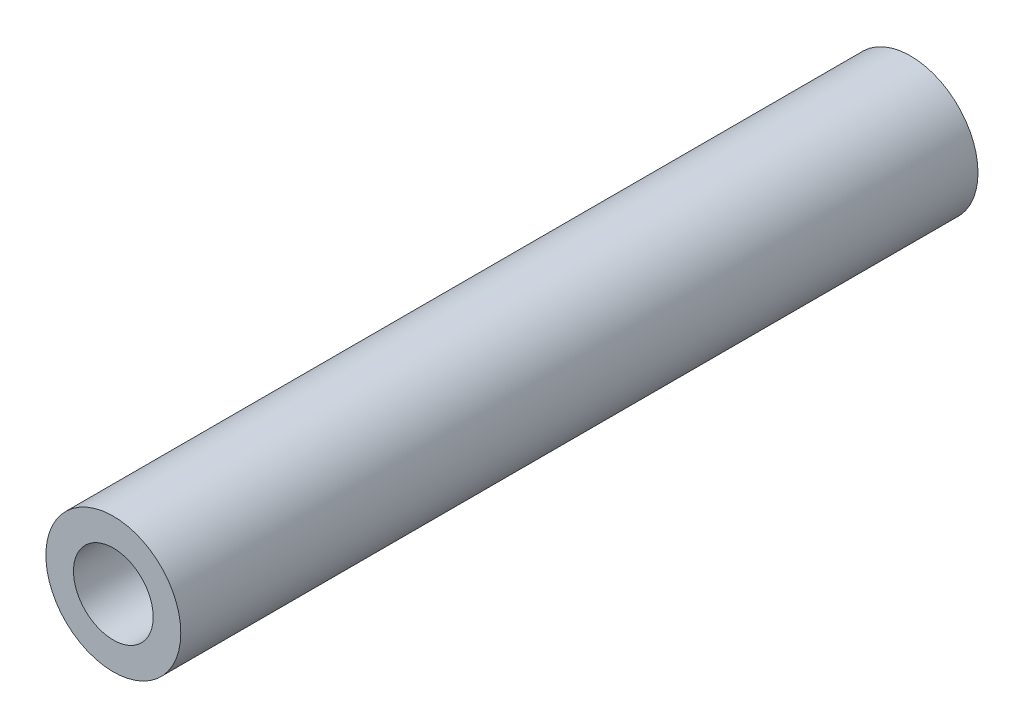
from build123d import *

# Parameters (mm, degrees)
CROQUIS2_R              = 11
CROQUIS2_R_2            = 6.5
SALIENTE_EXTRUIR1_DEPTH = 130


with BuildPart() as part:
    # Croquis2 → Saliente-Extruir1 (new body)
    with BuildSketch(Plane.XY):
        Circle(CROQUIS2_R)
        Circle(CROQUIS2_R_2, mode=Mode.SUBTRACT)
    extrude(amount=SALIENTE_EXTRUIR1_DEPTH)


solid = part.part
